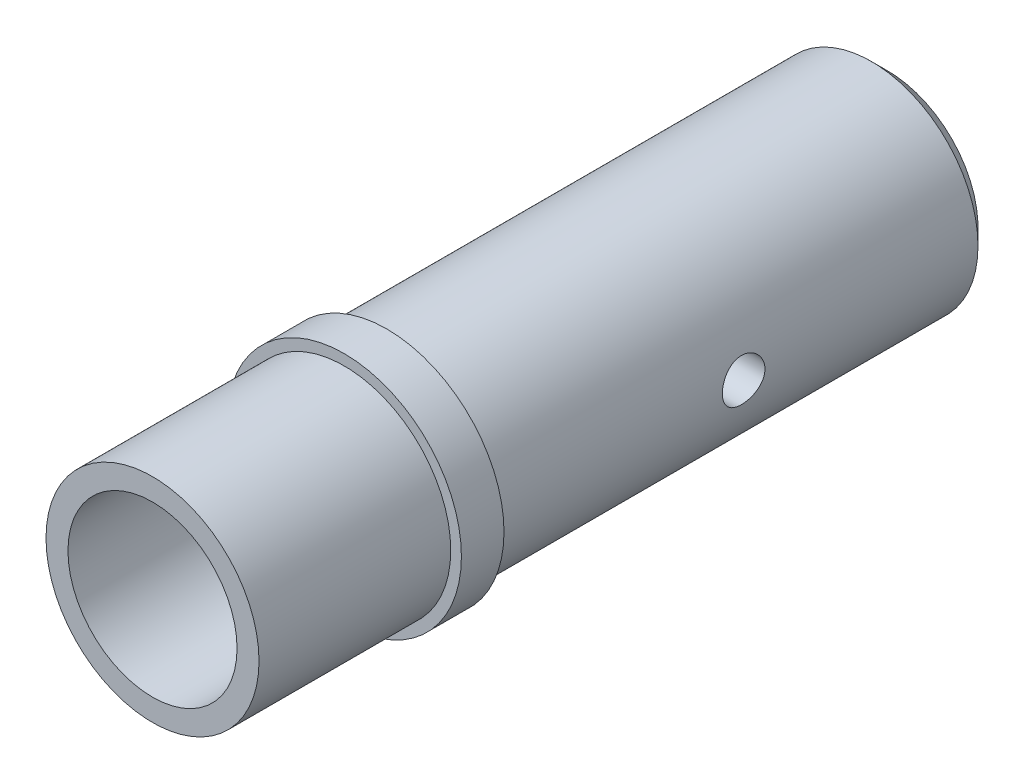
from build123d import *

# Parameters (mm, degrees)
SZKIC1_R                    = 10
SZKIC1_R_2                  = 7.9375
DODANIE_WYCI_GNI_CIE1_DEPTH = 18
SZKIC2_R                    = 11
SZKIC2_R_2                  = 7.9375
DODANIE_WYCI_GNI_CIE2_DEPTH = 4
SZKIC3_R                    = 10
SZKIC3_R_2                  = 6
DODANIE_WYCI_GNI_CIE3_DEPTH = 47
SFAZOWANIE1_SIZE            = 1.5
SZKIC6_R                    = 2
WYTNIJ_WYCI_GNI_CIE1_DEPTH  = 15


with BuildPart() as part:
    # Szkic1 → Dodanie-wyciągnięcie1 (new body)
    with BuildSketch(Plane.XY):
        Circle(SZKIC1_R)
        Circle(SZKIC1_R_2, mode=Mode.SUBTRACT)
    extrude(amount=DODANIE_WYCI_GNI_CIE1_DEPTH)

    # Szkic2 → Dodanie-wyciągnięcie2 (add)
    with BuildSketch(Plane(origin=(0, 0, 0), x_dir=(-1, 0, 0), z_dir=(0, 0, -1))):
        Circle(SZKIC2_R)
        Circle(SZKIC2_R_2, mode=Mode.SUBTRACT)
    extrude(amount=DODANIE_WYCI_GNI_CIE2_DEPTH)

    # Szkic3 → Dodanie-wyciągnięcie3 (add)
    with BuildSketch(Plane(origin=(0, 0, -4), x_dir=(-1, 0, 0), z_dir=(0, 0, -1))):
        Circle(SZKIC3_R)
        Circle(SZKIC3_R_2, mode=Mode.SUBTRACT)
    extrude(amount=DODANIE_WYCI_GNI_CIE3_DEPTH)

    # Sfazowanie1
    sfazowanie1_edges = [part.edges().sort_by_distance(p)[0] for p in [
        (10, 0, -51),
    ]]
    chamfer(sfazowanie1_edges, length=SFAZOWANIE1_SIZE)

    # Szkic6 → Wytnij-wyciągnięcie1 (cut, symmetric)
    with BuildSketch(Plane(origin=(0, 0, 0), x_dir=(0, 0, -1), z_dir=(1, 0, 0))):
        with Locations((27.5, 0)):
            Circle(SZKIC6_R)
    extrude(amount=WYTNIJ_WYCI_GNI_CIE1_DEPTH, both=True, mode=Mode.SUBTRACT)


solid = part.part
